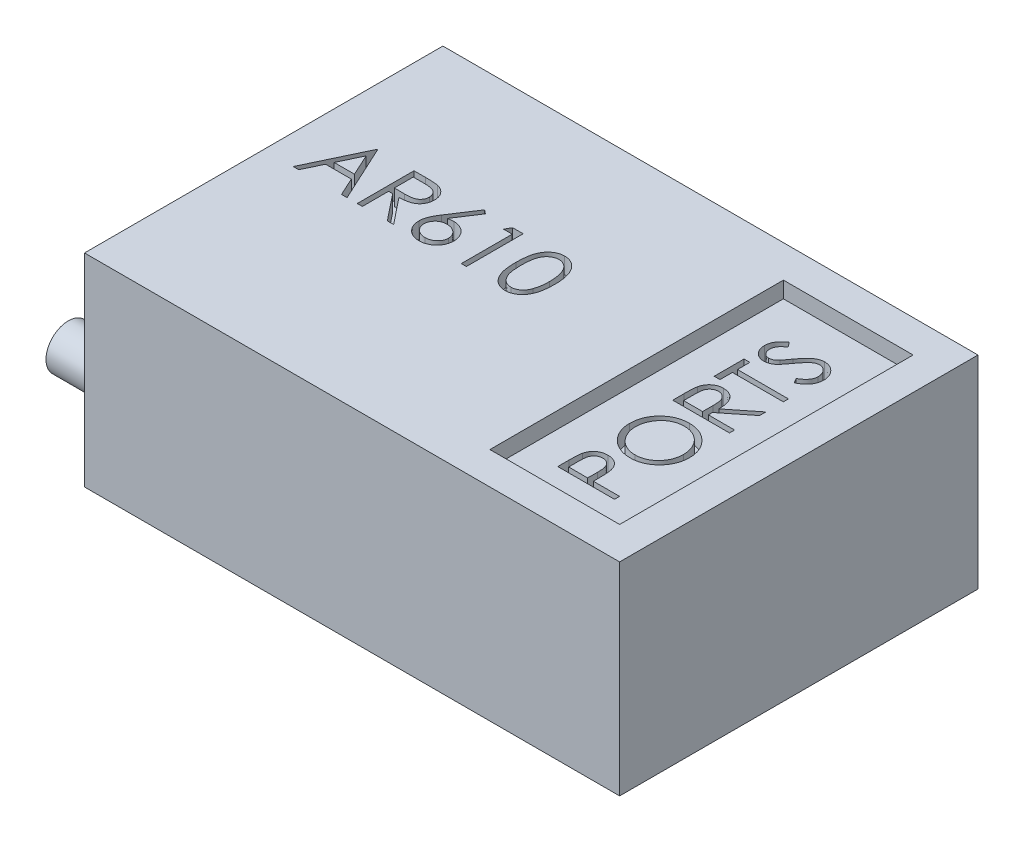
from build123d import *

# Parameters (mm, degrees)
SKETCH1_W           = 33
SKETCH1_H           = 22.1
BOSS_EXTRUDE1_DEPTH = 12.5
CUT_EXTRUDE1_START  = 12.5
SKETCH1_3_W         = 8
SKETCH1_3_H         = 18.1
CUT_EXTRUDE1_DEPTH  = 1
CUT_EXTRUDE2_DEPTH  = 1
CUT_EXTRUDE3_DEPTH  = 1
SKETCH4_R           = 1.375
BOSS_EXTRUDE2_DEPTH = 4
SKETCH5_R           = 1.375
BOSS_EXTRUDE3_DEPTH = 4


with BuildPart() as part:
    # Sketch1 → Boss-Extrude1 (new body)
    with BuildSketch(Plane(origin=(0, 0, 0), x_dir=(1, 0, 0), z_dir=(0, 1, 0))):
        Rectangle(SKETCH1_W, SKETCH1_H)
    extrude(amount=BOSS_EXTRUDE1_DEPTH)

    # Sketch1_3 → Cut-Extrude1 (cut)
    with BuildSketch(Plane(origin=(0, 0, 0), x_dir=(1, 0, 0), z_dir=(0, 1, 0)).offset(CUT_EXTRUDE1_START)):
        with Locations((10.5, 0)):
            Rectangle(SKETCH1_3_W, SKETCH1_3_H)
    extrude(amount=-CUT_EXTRUDE1_DEPTH, mode=Mode.SUBTRACT)

    # Sketch2 → Cut-Extrude2 (cut)
    with BuildSketch(Plane(origin=(0, 11.5, 0), x_dir=(1, 0, 0), z_dir=(0, 1, 0))):
        with BuildLine():
            Line((11.324819712, 4.891025641), (11.147435897, 5.186899038))
            add(Edge.make_bspline(
                [(11.147435897, 5.186899038), (11.193500282, 5.214417276), (11.281757866, 5.267141156), (11.401015907, 5.355092515), (11.502378063, 5.446225427), (11.585254671, 5.54121476), (11.650503558, 5.639480708), (11.696705789, 5.741664762), (11.725521765, 5.847422573), (11.729021851, 5.919396394), (11.730769231, 5.955328526)],
                knots=[0, 0, 0, 0, 0.000160901, 0.00030828, 0.000443778, 0.00056903, 0.000685513, 0.000796284, 0.00090427, 0.001011928, 0.001011928, 0.001011928, 0.001011928], degree=3))
            add(Edge.make_bspline(
                [(11.730769231, 5.955328526), (11.729894225, 5.986009174), (11.728159525, 6.04683363), (11.712164723, 6.13655253), (11.685997262, 6.22325154), (11.650524434, 6.306068819), (11.606920617, 6.382810251), (11.555503534, 6.451184154), (11.496092934, 6.508918667), (11.430889701, 6.556781277), (11.360969967, 6.593817016), (11.288927613, 6.621808988), (11.213774163, 6.637485999), (11.163161674, 6.639838471), (11.137620192, 6.641025641)],
                knots=[0, 0, 0, 0, 9.1978e-05, 0.000182347, 0.000272402, 0.000363175, 0.000452051, 0.000536609, 0.000618912, 0.000699687, 0.000778419, 0.000855638, 0.000930855, 0.001007482, 0.001007482, 0.001007482, 0.001007482], degree=3))
            add(Edge.make_bspline(
                [(11.137620192, 6.641025641), (11.108469616, 6.639582995), (11.049436521, 6.63666148), (10.962191104, 6.610913976), (10.875478842, 6.571598615), (10.821831619, 6.534646594), (10.794070513, 6.51552484)],
                knots=[0, 0, 0, 0, 8.7281e-05, 0.000176753, 0.00027087, 0.000371805, 0.000371805, 0.000371805, 0.000371805], degree=3))
            add(Edge.make_bspline(
                [(10.794070513, 6.51552484), (10.774021155, 6.499856523), (10.731930035, 6.466962851), (10.669329303, 6.410365002), (10.604625858, 6.344289395), (10.536399232, 6.269640382), (10.465216106, 6.186292744), (10.390521004, 6.094214233), (10.313840327, 5.992619013), (10.262479108, 5.921309671), (10.235977564, 5.884515224)],
                knots=[0, 0, 0, 0, 7.6319e-05, 0.000160223, 0.000252933, 0.000353672, 0.000463561, 0.00058171, 0.000709316, 0.00084535, 0.00084535, 0.00084535, 0.00084535], degree=3))
            add(Edge.make_bspline(
                [(10.235977564, 5.884515224), (10.209748976, 5.847691228), (10.159601914, 5.777286552), (10.08517763, 5.678827969), (10.017133761, 5.590783506), (9.954829749, 5.51354449), (9.898257144, 5.447144893), (9.847959205, 5.391061482), (9.802575644, 5.346722925), (9.773134302, 5.322067344), (9.759915865, 5.310997596)],
                knots=[0, 0, 0, 0, 0.000135623, 0.000259301, 0.000370234, 0.000469439, 0.00055697, 0.000631911, 0.000695377, 0.00074709, 0.00074709, 0.00074709, 0.00074709], degree=3))
            add(Edge.make_bspline(
                [(9.759915865, 5.310997596), (9.739313806, 5.295527644), (9.698797091, 5.265103908), (9.635486806, 5.224900947), (9.57080172, 5.190997681), (9.5045074, 5.16371189), (9.437102088, 5.141646905), (9.36807973, 5.12630608), (9.297908891, 5.11685032), (9.250697025, 5.115873567), (9.227063301, 5.115384615)],
                knots=[0, 0, 0, 0, 7.727e-05, 0.000151962, 0.000224716, 0.000296069, 0.000366799, 0.000437219, 0.000507921, 0.00057879, 0.00057879, 0.00057879, 0.00057879], degree=3))
            add(Edge.make_bspline(
                [(9.227063301, 5.115384615), (9.190033454, 5.116689766), (9.116765247, 5.119272171), (9.009735467, 5.141113532), (8.907545135, 5.175583284), (8.811229505, 5.223889972), (8.723208531, 5.28610319), (8.642689941, 5.358412416), (8.574076388, 5.443739272), (8.515061523, 5.538202444), (8.468392297, 5.641056543), (8.434570946, 5.749339544), (8.414481488, 5.862273073), (8.411678608, 5.938889047), (8.41025641, 5.977764423)],
                knots=[0, 0, 0, 0, 0.000110999, 0.000219625, 0.000326272, 0.00043382, 0.000541574, 0.000648775, 0.000757401, 0.00086888, 0.000982145, 0.001095241, 0.001208435, 0.001325032, 0.001325032, 0.001325032, 0.001325032], degree=3))
            add(Edge.make_bspline(
                [(8.41025641, 5.977764423), (8.411659646, 6.019015202), (8.414450233, 6.101049834), (8.439317515, 6.221525554), (8.478894919, 6.337993167), (8.525329582, 6.431268407), (8.571411516, 6.504424807), (8.613476125, 6.560159904), (8.661802416, 6.616946088), (8.717409181, 6.67417308), (8.779184228, 6.732405827), (8.84765049, 6.791376095), (8.922190972, 6.851635747), (8.975417749, 6.890389429), (9.002704327, 6.91025641)],
                knots=[0, 0, 0, 0, 0.000123638, 0.000245877, 0.00036738, 0.00049186, 0.00055741, 0.000626541, 0.000701144, 0.000780976, 0.000865789, 0.000955754, 0.001052002, 0.001153245, 0.001153245, 0.001153245, 0.001153245], degree=3))
            Line((9.002704327, 6.91025641), (9.217948718, 6.626302083))
            add(Edge.make_bspline(
                [(9.217948718, 6.626302083), (9.195858749, 6.609157401), (9.153318634, 6.576140751), (9.093764323, 6.525994636), (9.039290221, 6.478802335), (8.992099661, 6.431950702), (8.948658829, 6.389051048), (8.912126496, 6.346674872), (8.881348415, 6.306457476), (8.84844255, 6.255885213), (8.816810731, 6.191821741), (8.789025896, 6.112073028), (8.772542449, 6.0284507), (8.770343811, 5.971525978), (8.769230769, 5.942708333)],
                knots=[0, 0, 0, 0, 8.3877e-05, 0.000161528, 0.000233552, 0.000299993, 0.000360974, 0.000416642, 0.000467684, 0.000512802, 0.000597461, 0.000681273, 0.000765563, 0.000851983, 0.000851983, 0.000851983, 0.000851983], degree=3))
            add(Edge.make_bspline(
                [(8.769230769, 5.942708333), (8.770422628, 5.906543278), (8.772721016, 5.836802377), (8.79848339, 5.738021386), (8.837653343, 5.648599939), (8.894136008, 5.571951683), (8.961474223, 5.508664408), (9.038268715, 5.462316711), (9.123085244, 5.434606238), (9.182222228, 5.431214525), (9.212339744, 5.429487179)],
                knots=[0, 0, 0, 0, 0.000108248, 0.000208746, 0.00030414, 0.000399502, 0.000492276, 0.000579692, 0.000666608, 0.000756813, 0.000756813, 0.000756813, 0.000756813], degree=3))
            add(Edge.make_bspline(
                [(9.212339744, 5.429487179), (9.231086922, 5.429902764), (9.268842435, 5.430739723), (9.324357544, 5.441434705), (9.37957994, 5.4558952), (9.434315268, 5.478063832), (9.489802974, 5.508935487), (9.546826776, 5.549432487), (9.605877844, 5.600448334), (9.644285314, 5.639524965), (9.664563301, 5.66015625)],
                knots=[0, 0, 0, 0, 5.616e-05, 0.000113102, 0.00016906, 0.000227257, 0.000289705, 0.000359147, 0.000436716, 0.000523477, 0.000523477, 0.000523477, 0.000523477], degree=3))
            add(Edge.make_bspline(
                [(9.664563301, 5.66015625), (9.671400327, 5.667817622), (9.687643535, 5.68601929), (9.714235816, 5.719295215), (9.747038588, 5.763238014), (9.787625905, 5.816700215), (9.834707367, 5.880667576), (9.887680979, 5.955147133), (9.948266438, 6.039308665), (9.990623979, 6.099030581), (10.013020833, 6.130608974)],
                knots=[0, 0, 0, 0, 3.0802e-05, 7.3177e-05, 0.000127725, 0.000195314, 0.000274544, 0.000365991, 0.000469501, 0.000585644, 0.000585644, 0.000585644, 0.000585644], degree=3))
            add(Edge.make_bspline(
                [(10.013020833, 6.130608974), (10.040662212, 6.168594861), (10.094185912, 6.242149265), (10.174601328, 6.346807208), (10.253250001, 6.441699774), (10.32962457, 6.527167148), (10.403162781, 6.60403017), (10.474692352, 6.671514016), (10.543744202, 6.729924878), (10.631670956, 6.79366713), (10.740659387, 6.858027909), (10.874250962, 6.913211987), (11.008225903, 6.948319153), (11.098156806, 6.952878605), (11.142528045, 6.955128205)],
                knots=[0, 0, 0, 0, 0.000140932, 0.000272896, 0.000395881, 0.000510584, 0.000616697, 0.000714904, 0.000805482, 0.000887803, 0.001040519, 0.001183872, 0.00132042, 0.001453406, 0.001453406, 0.001453406, 0.001453406], degree=3))
            add(Edge.make_bspline(
                [(11.142528045, 6.955128205), (11.173906078, 6.954470397), (11.236052803, 6.953167556), (11.327312713, 6.938216381), (11.415925606, 6.916260494), (11.500708518, 6.883434617), (11.583021811, 6.842716087), (11.661314865, 6.791788931), (11.737108745, 6.732449155), (11.808278554, 6.664414283), (11.873692779, 6.590006612), (11.931641285, 6.511079761), (11.981071825, 6.428457656), (12.020438404, 6.341245554), (12.051434888, 6.250380345), (12.073830506, 6.155562389), (12.087590898, 6.056695638), (12.089018015, 5.989494776), (12.08974359, 5.955328526)],
                knots=[0, 0, 0, 0, 9.4044e-05, 0.000186263, 0.000276729, 0.000367488, 0.000458418, 0.00055177, 0.000647146, 0.000746826, 0.000846684, 0.000944006, 0.0010402, 0.001134956, 0.001230517, 0.001327791, 0.001426848, 0.001529298, 0.001529298, 0.001529298, 0.001529298], degree=3))
            add(Edge.make_bspline(
                [(12.08974359, 5.955328526), (12.089232408, 5.928893183), (12.088216483, 5.876355423), (12.079235203, 5.79864594), (12.066528096, 5.722506355), (12.046354038, 5.648892058), (12.021877016, 5.5768547), (11.991738854, 5.506707265), (11.955621006, 5.43841697), (11.914328466, 5.371596474), (11.866261053, 5.306433633), (11.810326101, 5.243468982), (11.747949935, 5.181046097), (11.67816895, 5.119607785), (11.600215796, 5.060494436), (11.515251617, 5.002286928), (11.42302375, 4.945268932), (11.358165806, 4.909444455), (11.324819712, 4.891025641)],
                knots=[0, 0, 0, 0, 7.9276e-05, 0.000157554, 0.000234438, 0.000310629, 0.000386236, 0.000462555, 0.000539392, 0.000617798, 0.000698008, 0.000781971, 0.000870217, 0.000962622, 0.001060644, 0.00116352, 0.001271506, 0.001385778, 0.001385778, 0.001385778, 0.001385778], degree=3))
        make_face()
        Polygon((8.858974359, 2.782051282), (8.5, 2.782051282), (8.5, 4.621794872), (8.858974359, 4.621794872), (8.858974359, 3.858974359), (12, 3.858974359), (12, 3.544871795), (8.858974359, 3.544871795), align=None)
        with BuildLine():
            Line((8.5, 0.224358974), (8.5, 0.924779647))
            add(Edge.make_bspline(
                [(8.5, 0.924779647), (8.500155586, 0.971520776), (8.500454328, 1.06126892), (8.502120091, 1.189842191), (8.506894447, 1.306669288), (8.51100303, 1.411689127), (8.518494972, 1.504899782), (8.525655619, 1.586587073), (8.53502928, 1.65637477), (8.543734703, 1.698620622), (8.547676282, 1.717748397)],
                knots=[0, 0, 0, 0, 0.000140226, 0.00026925, 0.000385712, 0.000490995, 0.000584507, 0.000666202, 0.000736998, 0.000795574, 0.000795574, 0.000795574, 0.000795574], degree=3))
            add(Edge.make_bspline(
                [(8.547676282, 1.717748397), (8.554003064, 1.743355002), (8.566521662, 1.794021952), (8.592981015, 1.866972307), (8.623601552, 1.936485565), (8.659561947, 2.002279275), (8.701149074, 2.064000637), (8.747570963, 2.122372975), (8.798733851, 2.17720681), (8.855098955, 2.227786515), (8.915465334, 2.273730647), (8.979667312, 2.314030727), (9.047439425, 2.348083554), (9.118887235, 2.374806282), (9.193221492, 2.397229588), (9.271200889, 2.412295287), (9.352565107, 2.421679745), (9.407926436, 2.422606838), (9.435997596, 2.423076923)],
                knots=[0, 0, 0, 0, 7.9081e-05, 0.000156475, 0.000232432, 0.000306798, 0.00038108, 0.000455429, 0.000530331, 0.000605792, 0.000682355, 0.00075764, 0.000832893, 0.000909456, 0.000986216, 0.001065554, 0.001147393, 0.001231575, 0.001231575, 0.001231575, 0.001231575], degree=3))
            add(Edge.make_bspline(
                [(9.435997596, 2.423076923), (9.482632701, 2.421607925), (9.573629869, 2.418741529), (9.70569075, 2.392016425), (9.828880065, 2.348239906), (9.943042703, 2.287916617), (10.045953348, 2.211097141), (10.136343803, 2.11877235), (10.211983716, 2.010890738), (10.264436521, 1.910461423), (10.298029429, 1.821747223), (10.321665788, 1.74871391), (10.339927753, 1.669046933), (10.356287885, 1.583509598), (10.36863958, 1.491745942), (10.377686174, 1.393975903), (10.383340223, 1.290129751), (10.384182228, 1.218790682), (10.384615385, 1.182091346)],
                knots=[0, 0, 0, 0, 0.000139777, 0.000272741, 0.000402249, 0.000530843, 0.000658588, 0.000786009, 0.000916741, 0.001052522, 0.001124656, 0.001201155, 0.001282612, 0.001369656, 0.001462366, 0.001560247, 0.001664165, 0.001774261, 0.001774261, 0.001774261, 0.001774261], degree=3))
            Line((10.384615385, 1.182091346), (12, 2.467948718))
            Line((12, 2.467948718), (12, 2.079527244))
            Line((12, 2.079527244), (10.384615385, 0.793669872))
            Line((10.384615385, 0.793669872), (10.384615385, 0.538461538))
            Line((10.384615385, 0.538461538), (12, 0.538461538))
            Line((12, 0.538461538), (12, 0.224358974))
            Line((12, 0.224358974), (8.5, 0.224358974))
        make_face()
        with BuildLine():
            Line((8.858974359, 0.538461538), (10.025641026, 0.538461538))
            Line((10.025641026, 0.538461538), (10.030548878, 1.179286859))
            add(Edge.make_bspline(
                [(10.030548878, 1.179286859), (10.030562123, 1.209206902), (10.030587794, 1.267200466), (10.026593914, 1.351101079), (10.02205095, 1.42922137), (10.015100421, 1.501261523), (10.006148236, 1.567257067), (9.994932575, 1.627164059), (9.981921822, 1.681116033), (9.961575546, 1.743835854), (9.930748318, 1.814700234), (9.882868093, 1.890030588), (9.825336481, 1.95612693), (9.757650075, 2.009957492), (9.68441132, 2.055058732), (9.604870116, 2.085410073), (9.521606702, 2.105637954), (9.464398252, 2.107849402), (9.435296474, 2.108974359)],
                knots=[0, 0, 0, 0, 8.9746e-05, 0.000173954, 0.000251933, 0.000324488, 0.000391021, 0.000451663, 0.000507268, 0.000557378, 0.000649353, 0.000738241, 0.000824182, 0.000910906, 0.000996758, 0.001081126, 0.001165314, 0.001252481, 0.001252481, 0.001252481, 0.001252481], degree=3))
            add(Edge.make_bspline(
                [(9.435296474, 2.108974359), (9.407152196, 2.107768768), (9.351380505, 2.105379727), (9.269690948, 2.085981825), (9.192568424, 2.052819171), (9.119913357, 2.009193553), (9.054992053, 1.954443216), (8.998841303, 1.891478684), (8.952874184, 1.820312076), (8.922322772, 1.754383063), (8.904381275, 1.694982342), (8.891340833, 1.643653307), (8.88229028, 1.585371229), (8.873717756, 1.520401159), (8.866778066, 1.448619104), (8.861991163, 1.369814677), (8.859187737, 1.284476047), (8.85904714, 1.225329383), (8.858974359, 1.194711538)],
                knots=[0, 0, 0, 0, 8.4371e-05, 0.000167192, 0.000250141, 0.000335393, 0.000420495, 0.000503932, 0.000587553, 0.000673837, 0.000720849, 0.000773564, 0.000832579, 0.000897628, 0.000970183, 0.001048862, 0.001134445, 0.001226295, 0.001226295, 0.001226295, 0.001226295], degree=3))
            Line((8.858974359, 1.194711538), (8.858974359, 0.538461538))
        make_face(mode=Mode.SUBTRACT)
        with BuildLine():
            add(Edge.make_bspline(
                [(8.41025641, -2.355769231), (8.411870256, -2.290954059), (8.415039982, -2.163651713), (8.440104769, -1.976730191), (8.481358785, -1.797744453), (8.539618265, -1.6265916), (8.615144359, -1.463922571), (8.706886934, -1.309277945), (8.815403528, -1.163121176), (8.939100677, -1.02645832), (9.074569243, -0.901790135), (9.219590912, -0.792393155), (9.37234238, -0.700106479), (9.532831612, -0.624559783), (9.700683913, -0.56525062), (9.876840006, -0.524334454), (10.060146125, -0.498195518), (10.185173068, -0.495139848), (10.248597756, -0.493589744)],
                knots=[0, 0, 0, 0, 0.000194393, 0.000381804, 0.00056463, 0.000744667, 0.000923157, 0.001101717, 0.001283171, 0.001468332, 0.001653919, 0.001834669, 0.002012386, 0.002188335, 0.002365952, 0.002545365, 0.00273009, 0.002920281, 0.002920281, 0.002920281, 0.002920281], degree=3))
            add(Edge.make_bspline(
                [(10.248597756, -0.493589744), (10.311554876, -0.49514037), (10.435650654, -0.498196835), (10.617798777, -0.524355663), (10.792872295, -0.56543319), (10.960480991, -0.623825455), (11.120644264, -0.699430122), (11.273511369, -0.791852658), (11.418920391, -0.901042015), (11.555322226, -1.025180795), (11.680098323, -1.160907431), (11.7901557, -1.30537174), (11.88248255, -1.458119134), (11.958872657, -1.617566699), (12.016945826, -1.784966468), (12.05922501, -1.959100269), (12.085104461, -2.140916842), (12.088180245, -2.264771892), (12.08974359, -2.327724359)],
                knots=[0, 0, 0, 0, 0.000188789, 0.000372126, 0.000550857, 0.00072758, 0.000903529, 0.001081247, 0.001262557, 0.001448189, 0.001633775, 0.001814947, 0.001992065, 0.002168314, 0.002344376, 0.002522589, 0.002705231, 0.00289402, 0.00289402, 0.00289402, 0.00289402], degree=3))
            add(Edge.make_bspline(
                [(12.08974359, -2.327724359), (12.088194203, -2.391148678), (12.085139949, -2.516174894), (12.058958544, -2.699711929), (12.01801724, -2.875989673), (11.959507804, -3.044504024), (11.883890573, -3.205348954), (11.791686194, -3.358839037), (11.682279053, -3.504358184), (11.558112479, -3.64069993), (11.422940927, -3.765449129), (11.278106671, -3.874208504), (11.126451215, -3.966433618), (10.967553691, -4.04179695), (10.802182248, -4.101461409), (10.629233771, -4.142166228), (10.449694265, -4.16850218), (10.327451366, -4.171537026), (10.265424679, -4.173076923)],
                knots=[0, 0, 0, 0, 0.00019019, 0.000374915, 0.000555011, 0.000732396, 0.00090898, 0.001087298, 0.001268608, 0.00145424, 0.001639827, 0.001819595, 0.001996712, 0.002171394, 0.002346367, 0.002523053, 0.002703612, 0.002889599, 0.002889599, 0.002889599, 0.002889599], degree=3))
            add(Edge.make_bspline(
                [(10.265424679, -4.173076923), (10.22379201, -4.172542288), (10.141051887, -4.171479761), (10.018185287, -4.158688069), (9.897294629, -4.140126368), (9.778723681, -4.113524455), (9.662762696, -4.078732788), (9.548611933, -4.037680761), (9.43742821, -3.987540915), (9.328684818, -3.930860267), (9.224076912, -3.867598459), (9.125197329, -3.79772271), (9.031216332, -3.723687341), (8.944569328, -3.642523948), (8.862735672, -3.556907502), (8.786972955, -3.465449124), (8.716598004, -3.36870688), (8.653177663, -3.2662645), (8.595818528, -3.160646225), (8.546596677, -3.051769448), (8.504350616, -2.941112876), (8.470109791, -2.828158228), (8.443077755, -2.713205456), (8.424670401, -2.596003671), (8.411846083, -2.476646245), (8.410788581, -2.396234926), (8.41025641, -2.355769231)],
                knots=[0, 0, 0, 0, 0.000124849, 0.000248123, 0.000370193, 0.00049164, 0.000612319, 0.000733199, 0.000855287, 0.000977905, 0.001100913, 0.001221706, 0.001340948, 0.001459521, 0.001577551, 0.001696047, 0.001815534, 0.001936153, 0.002057243, 0.002175846, 0.002294342, 0.002412335, 0.002529682, 0.00264829, 0.002768075, 0.00288942, 0.00288942, 0.00288942, 0.00288942], degree=3))
        make_face()
        with BuildLine():
            add(Edge.make_bspline(
                [(8.769230769, -2.340344551), (8.769634247, -2.37355961), (8.770437346, -2.439672188), (8.78107394, -2.537950444), (8.796125217, -2.634966024), (8.817984948, -2.730531189), (8.846259561, -2.824846358), (8.880360976, -2.917953402), (8.921577647, -3.009533089), (8.967930801, -3.099471009), (9.020580569, -3.185689891), (9.07648948, -3.268397375), (9.137734853, -3.345442169), (9.202992164, -3.417882654), (9.272827745, -3.485538676), (9.346782977, -3.548380394), (9.425177738, -3.606356274), (9.507689399, -3.658768603), (9.59385728, -3.705411484), (9.682034222, -3.747172811), (9.773256487, -3.781791358), (9.866954822, -3.809214404), (9.962716319, -3.832490288), (10.06106272, -3.847090644), (10.161654991, -3.857832041), (10.229637232, -3.858590655), (10.264022436, -3.858974359)],
                knots=[0, 0, 0, 0, 9.9599e-05, 0.000198245, 0.000296222, 0.00039402, 0.000492067, 0.000591444, 0.000691249, 0.000793166, 0.00089477, 0.000994144, 0.001092474, 0.001189771, 0.001286457, 0.001383951, 0.001480708, 0.001578737, 0.001676939, 0.001774486, 0.001871236, 0.001969283, 0.002067239, 0.002166601, 0.002267341, 0.002370444, 0.002370444, 0.002370444, 0.002370444], degree=3))
            add(Edge.make_bspline(
                [(10.264022436, -3.858974359), (10.314583507, -3.85769658), (10.414052776, -3.855182794), (10.559837321, -3.83326684), (10.700078846, -3.799240157), (10.833941455, -3.749907894), (10.962022079, -3.686974857), (11.083822274, -3.610209329), (11.19930611, -3.518908299), (11.307613927, -3.415259346), (11.406431406, -3.301921948), (11.49329249, -3.181631994), (11.566397201, -3.055341173), (11.627511096, -2.923777392), (11.673551763, -2.785817383), (11.706378736, -2.642345692), (11.727654831, -2.493359149), (11.729721246, -2.391833454), (11.730769231, -2.340344551)],
                knots=[0, 0, 0, 0, 0.000151605, 0.000298253, 0.000441263, 0.000583887, 0.000725302, 0.000868664, 0.001014957, 0.001166206, 0.001317773, 0.001465459, 0.001610604, 0.001754915, 0.001899916, 0.002046009, 0.002196031, 0.002350407, 0.002350407, 0.002350407, 0.002350407], degree=3))
            add(Edge.make_bspline(
                [(11.730769231, -2.340344551), (11.73029411, -2.305734913), (11.729351803, -2.237093607), (11.719847504, -2.13500008), (11.704636733, -2.034736379), (11.682628178, -1.936487754), (11.655447833, -1.84012548), (11.621733416, -1.745940317), (11.581317911, -1.653963545), (11.536276167, -1.563742896), (11.485109961, -1.477298497), (11.429954753, -1.395092698), (11.369790032, -1.31818064), (11.305409155, -1.245774143), (11.235788248, -1.178592275), (11.162282468, -1.115929481), (11.083721323, -1.05895602), (11.00154761, -1.00672137), (10.916007946, -0.959509375), (10.827588586, -0.918956006), (10.736763755, -0.884322589), (10.643466721, -0.856404132), (10.547907348, -0.834515957), (10.449948869, -0.819436774), (10.349789635, -0.808888136), (10.282045764, -0.808093086), (10.247896635, -0.807692308)],
                knots=[0, 0, 0, 0, 0.000103804, 0.000205874, 0.000307314, 0.000407849, 0.000507719, 0.000607515, 0.00070768, 0.000808957, 0.000909843, 0.001008823, 0.001105735, 0.001202564, 0.00129925, 0.001395755, 0.001492098, 0.001590127, 0.001687714, 0.001784966, 0.001881715, 0.00197909, 0.002076889, 0.002175558, 0.002276298, 0.0023787, 0.0023787, 0.0023787, 0.0023787], degree=3))
            add(Edge.make_bspline(
                [(10.247896635, -0.807692308), (10.21398113, -0.808093421), (10.14670348, -0.808889102), (10.047242662, -0.819431577), (9.94998945, -0.834532467), (9.855325648, -0.856295175), (9.763227121, -0.884345328), (9.673780379, -0.918932662), (9.586652163, -0.959717948), (9.502057945, -1.006526226), (9.420882913, -1.059141849), (9.34328159, -1.116636835), (9.270704782, -1.179999411), (9.201385299, -1.247435805), (9.136709676, -1.320567335), (9.076927808, -1.399406764), (9.019346124, -1.481991093), (8.968385696, -1.570187906), (8.9210882, -1.660883674), (8.880736177, -1.754033316), (8.846079504, -1.848306518), (8.817900543, -1.944080203), (8.79620895, -2.041309099), (8.781060471, -2.139936664), (8.770441, -2.239618633), (8.76963546, -2.306662699), (8.769230769, -2.340344551)],
                knots=[0, 0, 0, 0, 0.000101701, 0.000201743, 0.00029972, 0.000396835, 0.000492868, 0.000588308, 0.000684288, 0.000781261, 0.000878109, 0.000974304, 0.001070733, 0.001166917, 0.001264269, 0.001363274, 0.001463623, 0.001566073, 0.001668612, 0.001770342, 0.001870377, 0.001969768, 0.002069618, 0.00216898, 0.002269022, 0.002370022, 0.002370022, 0.002370022, 0.002370022], degree=3))
        make_face(mode=Mode.SUBTRACT)
        with BuildLine():
            Line((8.5, -6.865384615), (8.5, -6.178986378))
            add(Edge.make_bspline(
                [(8.5, -6.178986378), (8.500051896, -6.131775472), (8.500151332, -6.041317279), (8.503166078, -5.911602224), (8.50719277, -5.793792492), (8.512774663, -5.688142111), (8.519371253, -5.594326013), (8.528623292, -5.512768713), (8.538283588, -5.442829157), (8.548104995, -5.400922708), (8.552584135, -5.381810897)],
                knots=[0, 0, 0, 0, 0.000141628, 0.000271366, 0.00038923, 0.000495248, 0.00058876, 0.000671296, 0.000741499, 0.00080036, 0.00080036, 0.00080036, 0.00080036], degree=3))
            add(Edge.make_bspline(
                [(8.552584135, -5.381810897), (8.559206344, -5.357617575), (8.572294717, -5.309801014), (8.598504692, -5.240896918), (8.629600774, -5.175354407), (8.664973264, -5.112880947), (8.706363357, -5.054614393), (8.751017547, -4.998612397), (8.801821577, -4.946851825), (8.857173072, -4.898631589), (8.916370005, -4.854062962), (8.980487907, -4.816617256), (9.047612511, -4.783875897), (9.118656095, -4.757068886), (9.193687635, -4.737134078), (9.272173907, -4.722334492), (9.354203167, -4.712897729), (9.410263789, -4.711996992), (9.438802083, -4.711538462)],
                knots=[0, 0, 0, 0, 7.5216e-05, 0.00014866, 0.000220794, 0.000292713, 0.000363707, 0.00043499, 0.000507379, 0.00058092, 0.0006551, 0.00072929, 0.000803294, 0.000878953, 0.00095668, 0.001035885, 0.001118421, 0.001204004, 0.001204004, 0.001204004, 0.001204004], degree=3))
            add(Edge.make_bspline(
                [(9.438802083, -4.711538462), (9.46757986, -4.711959886), (9.523885524, -4.712784432), (9.606258312, -4.722680718), (9.684976702, -4.736010909), (9.759866153, -4.756507961), (9.830481923, -4.783353635), (9.897903155, -4.814845687), (9.960982827, -4.852829218), (10.019949945, -4.896474048), (10.074859857, -4.945025642), (10.125314652, -4.99827858), (10.17101899, -5.056017873), (10.212075334, -5.118060021), (10.247531613, -5.185009869), (10.279288918, -5.255852023), (10.305959979, -5.331202239), (10.31999004, -5.383344753), (10.327123397, -5.409855769)],
                knots=[0, 0, 0, 0, 8.6284e-05, 0.00016882, 0.000248587, 0.000325638, 0.000401297, 0.000474998, 0.000548586, 0.000621785, 0.0006948, 0.0007682, 0.000841564, 0.000915458, 0.000991056, 0.00106858, 0.00114819, 0.001230532, 0.001230532, 0.001230532, 0.001230532], degree=3))
            add(Edge.make_bspline(
                [(10.327123397, -5.409855769), (10.331782903, -5.431783353), (10.341994481, -5.479838927), (10.353472009, -5.558976687), (10.362884836, -5.65116331), (10.371668962, -5.756085135), (10.37632345, -5.873986838), (10.381788578, -6.004598009), (10.384367274, -6.14836068), (10.384530279, -6.248630661), (10.384615385, -6.300981571)],
                knots=[0, 0, 0, 0, 6.7238e-05, 0.000147357, 0.000239727, 0.000345231, 0.000463153, 0.000593654, 0.000737411, 0.000894464, 0.000894464, 0.000894464, 0.000894464], degree=3))
            Line((10.384615385, -6.300981571), (10.384615385, -6.551282051))
            Line((10.384615385, -6.551282051), (12, -6.551282051))
            Line((12, -6.551282051), (12, -6.865384615))
            Line((12, -6.865384615), (8.5, -6.865384615))
        make_face()
        with BuildLine():
            Line((8.858974359, -6.551282051), (10.025641026, -6.551282051))
            Line((10.025641026, -6.551282051), (10.033353365, -5.938501603))
            add(Edge.make_bspline(
                [(10.033353365, -5.938501603), (10.033369841, -5.908581468), (10.033401646, -5.850821264), (10.029402888, -5.767387839), (10.024848287, -5.689969055), (10.017959717, -5.61885604), (10.008929892, -5.553799271), (9.997700403, -5.49536068), (9.985492161, -5.442666223), (9.965095217, -5.382051459), (9.933732824, -5.313918466), (9.888077864, -5.239488373), (9.828934043, -5.1768982), (9.762621316, -5.122835038), (9.68904981, -5.079087992), (9.609918632, -5.048226197), (9.526400101, -5.029222777), (9.469284935, -5.026849432), (9.440204327, -5.025641026)],
                knots=[0, 0, 0, 0, 8.9746e-05, 0.000173253, 0.000250533, 0.00032239, 0.000387534, 0.000447487, 0.000500883, 0.00054966, 0.000639077, 0.000725438, 0.000810285, 0.000896023, 0.000981517, 0.001065885, 0.001149917, 0.001237085, 0.001237085, 0.001237085, 0.001237085], degree=3))
            add(Edge.make_bspline(
                [(9.440204327, -5.025641026), (9.412065841, -5.026903685), (9.356130013, -5.029413694), (9.274150847, -5.048069373), (9.19591669, -5.079419391), (9.122937667, -5.122873284), (9.056770854, -5.175624417), (8.999194105, -5.236887546), (8.953217687, -5.306819403), (8.922399559, -5.371329886), (8.904356633, -5.42909823), (8.891324885, -5.47902804), (8.882338596, -5.535692535), (8.873739839, -5.598553316), (8.866798926, -5.667530572), (8.861978891, -5.743062707), (8.859187578, -5.824898191), (8.859047153, -5.881708495), (8.858974359, -5.911157853)],
                knots=[0, 0, 0, 0, 8.4371e-05, 0.000167719, 0.000250783, 0.000336277, 0.000421575, 0.000503926, 0.000587348, 0.000671722, 0.000717397, 0.000768752, 0.000826385, 0.000889349, 0.000959113, 0.001034294, 0.001116373, 0.001204717, 0.001204717, 0.001204717, 0.001204717], degree=3))
            Line((8.858974359, -5.911157853), (8.858974359, -6.551282051))
        make_face(mode=Mode.SUBTRACT)
    extrude(amount=-CUT_EXTRUDE2_DEPTH, mode=Mode.SUBTRACT)

    # Sketch3 → Cut-Extrude3 (cut)
    with BuildSketch(Plane(origin=(0, 12.5, 0), x_dir=(1, 0, 0), z_dir=(0, 1, 0))):
        with BuildLine():
            add(Edge.make_bspline(
                [(-2.698717949, 1.748597756), (-2.698389931, 1.804695144), (-2.697752751, 1.913665128), (-2.69066433, 2.07244977), (-2.678888987, 2.221410059), (-2.662751614, 2.360553125), (-2.643113634, 2.48991489), (-2.616898148, 2.609149647), (-2.587085345, 2.718809254), (-2.552532899, 2.819251302), (-2.51354511, 2.911829005), (-2.471110849, 2.998254207), (-2.423546055, 3.078396139), (-2.373569142, 3.153533929), (-2.31915707, 3.222437624), (-2.26185828, 3.286080287), (-2.199436404, 3.342991037), (-2.134013395, 3.394837339), (-2.064996931, 3.440286811), (-1.994354265, 3.48031955), (-1.921599159, 3.514519417), (-1.846532976, 3.541409853), (-1.769830418, 3.5636207), (-1.691223352, 3.578809647), (-1.610581988, 3.588366556), (-1.556150553, 3.589280224), (-1.528545673, 3.58974359)],
                knots=[0, 0, 0, 0, 0.000168282, 0.000326891, 0.000476705, 0.00061646, 0.000747059, 0.00086904, 0.000982494, 0.001087814, 0.001187428, 0.001283689, 0.001376399, 0.001466822, 0.001554203, 0.001639568, 0.001723424, 0.001807301, 0.001889751, 0.001971063, 0.002050735, 0.002130583, 0.002210036, 0.002290062, 0.002370508, 0.002453288, 0.002453288, 0.002453288, 0.002453288], degree=3))
            add(Edge.make_bspline(
                [(-1.528545673, 3.58974359), (-1.500710195, 3.589255775), (-1.445354186, 3.588285664), (-1.36351381, 3.578961721), (-1.283564129, 3.563490598), (-1.20584599, 3.541569623), (-1.129721004, 3.514373947), (-1.055784596, 3.48028683), (-0.983577514, 3.440607962), (-0.914247227, 3.393984085), (-0.847032611, 3.342001809), (-0.783584648, 3.28323914), (-0.723897563, 3.218289421), (-0.667222257, 3.147847557), (-0.61516666, 3.070562472), (-0.565593228, 2.987778362), (-0.521221192, 2.898047497), (-0.478486517, 2.80286703), (-0.44159953, 2.699603371), (-0.408333285, 2.58883861), (-0.381454316, 2.469264423), (-0.359065044, 2.341508178), (-0.341720148, 2.205100695), (-0.329087506, 2.060334379), (-0.322414421, 1.907113989), (-0.321157719, 1.80235614), (-0.320512821, 1.748597756)],
                knots=[0, 0, 0, 0, 8.3481e-05, 0.000166017, 0.000246731, 0.000327534, 0.000408041, 0.000488986, 0.000571522, 0.000654944, 0.000739373, 0.000826202, 0.000914021, 0.001003809, 0.001097153, 0.001193347, 0.001293057, 0.001397277, 0.001506176, 0.001621751, 0.001744038, 0.001873599, 0.002010742, 0.002156422, 0.002309427, 0.002470709, 0.002470709, 0.002470709, 0.002470709], degree=3))
            add(Edge.make_bspline(
                [(-0.320512821, 1.748597756), (-0.321164405, 1.695073848), (-0.322433991, 1.590784697), (-0.329012698, 1.438253721), (-0.341971329, 1.294255678), (-0.358181317, 1.158445216), (-0.38063228, 1.031387597), (-0.408237446, 0.912643148), (-0.438887769, 0.801699077), (-0.476722563, 0.699464265), (-0.518133274, 0.604512542), (-0.56318847, 0.515845394), (-0.611458296, 0.432679101), (-0.664047041, 0.355679354), (-0.720100454, 0.284300697), (-0.780818243, 0.219803074), (-0.844488828, 0.160632402), (-0.911901244, 0.107980775), (-0.982312795, 0.06189597), (-1.054271872, 0.02068212), (-1.129055255, -0.012550575), (-1.204968208, -0.041085616), (-1.283096574, -0.062886068), (-1.363342965, -0.077959923), (-1.445299201, -0.088531772), (-1.500700766, -0.089338252), (-1.528545673, -0.08974359)],
                knots=[0, 0, 0, 0, 0.000160581, 0.000312886, 0.000457868, 0.000594226, 0.000723097, 0.000844701, 0.000959884, 0.001068125, 0.001171421, 0.001270505, 0.001366343, 0.001459687, 0.001550023, 0.00163832, 0.001725149, 0.001810562, 0.001894568, 0.001977446, 0.00205903, 0.002139777, 0.00222058, 0.002301983, 0.002384599, 0.00246808, 0.00246808, 0.00246808, 0.00246808], degree=3))
            add(Edge.make_bspline(
                [(-1.528545673, -0.08974359), (-1.556149787, -0.089277234), (-1.610579712, -0.088357672), (-1.691232137, -0.078843941), (-1.769514581, -0.063548438), (-1.845813335, -0.042131834), (-1.92051985, -0.015916997), (-1.992616136, 0.018236686), (-2.06290382, 0.057570755), (-2.131195376, 0.102366177), (-2.196207537, 0.15368786), (-2.258306143, 0.210452149), (-2.315931162, 0.27407556), (-2.369565257, 0.343553483), (-2.420539345, 0.418246725), (-2.467428719, 0.499175098), (-2.510799573, 0.586017709), (-2.550443064, 0.67933562), (-2.585591727, 0.780490547), (-2.616639435, 0.890639726), (-2.641153593, 1.010755362), (-2.662136548, 1.139872729), (-2.679060931, 1.278546659), (-2.690615256, 1.426852438), (-2.697756571, 1.584697647), (-2.698391642, 1.692967421), (-2.698717949, 1.748597756)],
                knots=[0, 0, 0, 0, 8.278e-05, 0.000163226, 0.000243252, 0.00032184, 0.00040079, 0.000480463, 0.00056082, 0.000642298, 0.000725191, 0.000809047, 0.000894412, 0.000982346, 0.001072188, 0.001165503, 0.001262704, 0.001363236, 0.001469448, 0.001583766, 0.001706286, 0.001836995, 0.001976138, 0.002125253, 0.002283161, 0.002450041, 0.002450041, 0.002450041, 0.002450041], degree=3))
        make_face()
        with BuildLine():
            add(Edge.make_bspline(
                [(-2.384615385, 1.75), (-2.384495938, 1.703251301), (-2.384264114, 1.612521256), (-2.378207914, 1.480677995), (-2.369957682, 1.357707667), (-2.359316384, 1.24345413), (-2.343513436, 1.138304118), (-2.325806648, 1.041534435), (-2.304258559, 0.953657197), (-2.278763541, 0.874069387), (-2.249724444, 0.801420318), (-2.21801858, 0.733819103), (-2.183957857, 0.670467167), (-2.145838707, 0.611933558), (-2.104323643, 0.558027394), (-2.060350384, 0.507794562), (-2.0122778, 0.462997581), (-1.945774057, 0.409270726), (-1.857977583, 0.353751592), (-1.747357128, 0.305405502), (-1.633688677, 0.275023046), (-1.556537427, 0.27115929), (-1.518028846, 0.269230769)],
                knots=[0, 0, 0, 0, 0.000140231, 0.000272162, 0.000395845, 0.00050998, 0.000616273, 0.00071473, 0.000805025, 0.000887508, 0.000965234, 0.00103957, 0.001111417, 0.001180842, 0.001248855, 0.001315406, 0.001380877, 0.0014457, 0.001571746, 0.00169106, 0.001806864, 0.001922266, 0.001922266, 0.001922266, 0.001922266], degree=3))
            add(Edge.make_bspline(
                [(-1.518028846, 0.269230769), (-1.479271174, 0.27082855), (-1.401835851, 0.274020813), (-1.288702056, 0.30481955), (-1.178871786, 0.35128909), (-1.092799846, 0.406236595), (-1.027317302, 0.458564925), (-0.980400312, 0.503179573), (-0.937338264, 0.55313544), (-0.896496189, 0.607034736), (-0.859037113, 0.66590722), (-0.824973976, 0.729469796), (-0.793890628, 0.797898973), (-0.776181582, 0.845668713), (-0.767127404, 0.870092147)],
                knots=[0, 0, 0, 0, 0.000116044, 0.000231848, 0.000349318, 0.000472837, 0.000536674, 0.000600645, 0.000666733, 0.000734322, 0.000803367, 0.000875831, 0.000950509, 0.001028633, 0.001028633, 0.001028633, 0.001028633], degree=3))
            add(Edge.make_bspline(
                [(-0.767127404, 0.870092147), (-0.756575636, 0.901321887), (-0.735151022, 0.964731651), (-0.707539248, 1.063095303), (-0.685793849, 1.166298067), (-0.666230483, 1.273723184), (-0.652877427, 1.386162885), (-0.642129614, 1.503269269), (-0.635798927, 1.625130631), (-0.635014176, 1.707925622), (-0.634615385, 1.75)],
                knots=[0, 0, 0, 0, 9.8886e-05, 0.00020078, 0.000306259, 0.000415188, 0.00052824, 0.000645799, 0.000767957, 0.000894177, 0.000894177, 0.000894177, 0.000894177], degree=3))
            add(Edge.make_bspline(
                [(-0.634615385, 1.75), (-0.635165574, 1.792067573), (-0.636241862, 1.874360737), (-0.640355849, 1.994878918), (-0.650979424, 2.109346679), (-0.662778543, 2.218257152), (-0.680175764, 2.321007454), (-0.698933571, 2.418457759), (-0.724134783, 2.509400784), (-0.751054558, 2.595260366), (-0.781864953, 2.675061021), (-0.815780688, 2.749174807), (-0.852002446, 2.817959532), (-0.891344687, 2.881226473), (-0.93334037, 2.939259016), (-0.979097919, 2.990893611), (-1.026802292, 3.037730579), (-1.093619478, 3.091193148), (-1.181093768, 3.145704843), (-1.289939415, 3.195870603), (-1.403210059, 3.224678896), (-1.479783513, 3.228740583), (-1.518028846, 3.230769231)],
                knots=[0, 0, 0, 0, 0.000126219, 0.000246912, 0.000361616, 0.00047102, 0.00057545, 0.000674176, 0.000768567, 0.000858368, 0.000944043, 0.001024988, 0.001102772, 0.001177091, 0.00124833, 0.001317386, 0.001383826, 0.001448649, 0.001573728, 0.001692043, 0.001806995, 0.001921698, 0.001921698, 0.001921698, 0.001921698], degree=3))
            add(Edge.make_bspline(
                [(-1.518028846, 3.230769231), (-1.556739438, 3.228737784), (-1.634231144, 3.22467119), (-1.748679099, 3.195977936), (-1.85838345, 3.14596497), (-1.945626425, 3.091012598), (-2.012490211, 3.038674287), (-2.059572905, 2.993287833), (-2.103719077, 2.943641578), (-2.144386777, 2.889239663), (-2.18247606, 2.830774296), (-2.217457073, 2.767785531), (-2.248974403, 2.699954167), (-2.278058939, 2.627337732), (-2.303631727, 2.547756787), (-2.32472569, 2.459987794), (-2.344212743, 2.363525902), (-2.358008012, 2.257806394), (-2.370271768, 2.14352424), (-2.378153116, 2.020246922), (-2.384284373, 1.888182542), (-2.384502838, 1.796983383), (-2.384615385, 1.75)],
                knots=[0, 0, 0, 0, 0.000116101, 0.000232413, 0.000351368, 0.000476447, 0.000540832, 0.000605795, 0.000672346, 0.000739935, 0.00080936, 0.000881545, 0.00095588, 0.001033607, 0.001116089, 0.001206384, 0.001304286, 0.001411174, 0.001526077, 0.001649061, 0.001781692, 0.001922624, 0.001922624, 0.001922624, 0.001922624], degree=3))
        make_face(mode=Mode.SUBTRACT)
        Polygon((-4.647135417, 3.5), (-4, 3.5), (-4, 0), (-4.314102564, 0), (-4.314102564, 3.141025641), (-4.852564103, 3.141025641), align=None)
        with BuildLine():
            Line((-6.467948718, 3.58974359), (-6.226061699, 3.399739583))
            Line((-6.226061699, 3.399739583), (-7.150841346, 1.985576923))
            add(Edge.make_bspline(
                [(-7.150841346, 1.985576923), (-7.089271069, 1.995390784), (-6.969171282, 2.014533829), (-6.847605384, 2.017691774), (-6.788361378, 2.019230769)],
                knots=[0, 0, 0, 0, 0.000186809, 0.000364392, 0.000364392, 0.000364392, 0.000364392], degree=3))
            add(Edge.make_bspline(
                [(-6.788361378, 2.019230769), (-6.752788882, 2.018274658), (-6.682765481, 2.01639258), (-6.579958679, 2.001908729), (-6.481169743, 1.979083617), (-6.386808131, 1.945811362), (-6.296535149, 1.903309007), (-6.209832753, 1.852370137), (-6.128330743, 1.790364457), (-6.050979564, 1.721099501), (-5.980752466, 1.644382516), (-5.918576411, 1.56298118), (-5.866349619, 1.476980299), (-5.823975697, 1.386423433), (-5.791070819, 1.291450173), (-5.767083174, 1.192182034), (-5.752903581, 1.088550562), (-5.75097809, 1.018072387), (-5.75, 0.982271635)],
                knots=[0, 0, 0, 0, 0.000106683, 0.000210003, 0.00031085, 0.000410412, 0.000509526, 0.000609808, 0.000711471, 0.00081622, 0.000920922, 0.001023007, 0.001123049, 0.001222163, 0.001322387, 0.001424078, 0.001528093, 0.001635477, 0.001635477, 0.001635477, 0.001635477], degree=3))
            add(Edge.make_bspline(
                [(-5.75, 0.982271635), (-5.751423105, 0.933291931), (-5.754223439, 0.836911465), (-5.782127235, 0.696534758), (-5.825486879, 0.562802243), (-5.887464408, 0.437849071), (-5.964446791, 0.321846502), (-6.058324383, 0.219061036), (-6.165767872, 0.127390999), (-6.28725467, 0.05073438), (-6.417997634, -0.011868671), (-6.555349631, -0.056833913), (-6.697976778, -0.084517383), (-6.794781386, -0.087987985), (-6.84375, -0.08974359)],
                knots=[0, 0, 0, 0, 0.000146776, 0.00028882, 0.000427614, 0.000567461, 0.000705914, 0.000843912, 0.000983689, 0.001128394, 0.001273595, 0.001417489, 0.001560911, 0.001707729, 0.001707729, 0.001707729, 0.001707729], degree=3))
            add(Edge.make_bspline(
                [(-6.84375, -0.08974359), (-6.890846701, -0.088215384), (-6.984137019, -0.085188276), (-7.121369813, -0.058222338), (-7.25323283, -0.014515235), (-7.378802211, 0.045699043), (-7.495122824, 0.121756926), (-7.599188461, 0.213319205), (-7.690480235, 0.31842867), (-7.766454856, 0.437069018), (-7.826713588, 0.564558975), (-7.871903513, 0.697496132), (-7.898299756, 0.835396113), (-7.901988313, 0.928877252), (-7.903846154, 0.975961538)],
                knots=[0, 0, 0, 0, 0.000141176, 0.000279646, 0.000417774, 0.000557008, 0.000696242, 0.000833365, 0.000971544, 0.001112541, 0.001254608, 0.001393623, 0.001532781, 0.001674001, 0.001674001, 0.001674001, 0.001674001], degree=3))
            add(Edge.make_bspline(
                [(-7.903846154, 0.975961538), (-7.902664709, 1.012006122), (-7.900252424, 1.085602274), (-7.883409034, 1.197066302), (-7.856344239, 1.311117383), (-7.826033992, 1.407871577), (-7.794008382, 1.487133099), (-7.767355843, 1.55103659), (-7.734181847, 1.616797663), (-7.698808466, 1.686671299), (-7.658051597, 1.758856731), (-7.613735947, 1.834560401), (-7.564636296, 1.912578329), (-7.530216134, 1.965522524), (-7.512620192, 1.992588141)],
                knots=[0, 0, 0, 0, 0.000108118, 0.000220757, 0.000337422, 0.000459596, 0.000524434, 0.000593848, 0.000667222, 0.000745302, 0.000828791, 0.000915849, 0.00100845, 0.001105299, 0.001105299, 0.001105299, 0.001105299], degree=3))
            Line((-7.512620192, 1.992588141), (-6.467948718, 3.58974359))
        make_face()
        with BuildLine():
            add(Edge.make_bspline(
                [(-6.854266827, 1.66025641), (-6.880929072, 1.659478367), (-6.933008181, 1.657958621), (-7.009415596, 1.649133369), (-7.081728847, 1.632514304), (-7.150905981, 1.611347972), (-7.215653684, 1.582244912), (-7.276442524, 1.546893113), (-7.333507576, 1.505271935), (-7.386251127, 1.457971024), (-7.434070791, 1.406182991), (-7.475251921, 1.350713469), (-7.510774322, 1.292899266), (-7.53965614, 1.232257323), (-7.562146216, 1.168810824), (-7.578414467, 1.102851574), (-7.587468218, 1.033937268), (-7.58897445, 0.987204766), (-7.58974359, 0.963341346)],
                knots=[0, 0, 0, 0, 8.0005e-05, 0.000156272, 0.000230267, 0.000302332, 0.000372951, 0.000442698, 0.000512957, 0.000584457, 0.000654919, 0.00072405, 0.000791387, 0.000858185, 0.000925156, 0.000993006, 0.001061623, 0.001133223, 0.001133223, 0.001133223, 0.001133223], degree=3))
            add(Edge.make_bspline(
                [(-7.58974359, 0.963341346), (-7.589117228, 0.939691366), (-7.587889027, 0.893317277), (-7.576736707, 0.824978097), (-7.559701624, 0.759213189), (-7.534361229, 0.69636159), (-7.50413434, 0.635465272), (-7.464229016, 0.578729986), (-7.42001223, 0.522709916), (-7.367158297, 0.471708445), (-7.310434934, 0.424251821), (-7.249833731, 0.382771567), (-7.186673772, 0.347285394), (-7.12010235, 0.319474296), (-7.051063966, 0.296650009), (-6.978983412, 0.28058853), (-6.903810556, 0.271508004), (-6.852888618, 0.26999981), (-6.826923077, 0.269230769)],
                knots=[0, 0, 0, 0, 7.09e-05, 0.000139024, 0.000207221, 0.000274272, 0.000342002, 0.000410648, 0.000481932, 0.000555803, 0.000630491, 0.000703613, 0.000775798, 0.000847422, 0.000919703, 0.000993697, 0.001068572, 0.001146476, 0.001146476, 0.001146476, 0.001146476], degree=3))
            add(Edge.make_bspline(
                [(-6.826923077, 0.269230769), (-6.800957578, 0.269999871), (-6.750035724, 0.271508182), (-6.674862264, 0.280587851), (-6.602783945, 0.296652499), (-6.533737436, 0.31946527), (-6.467196005, 0.347318879), (-6.404091284, 0.382550799), (-6.34406319, 0.424506917), (-6.287302591, 0.471627345), (-6.234668652, 0.523000197), (-6.189391373, 0.578229919), (-6.15070814, 0.635923815), (-6.119273953, 0.696121704), (-6.094212662, 0.759251192), (-6.077091195, 0.824967916), (-6.065961906, 0.893319942), (-6.064730539, 0.939692266), (-6.064102564, 0.963341346)],
                knots=[0, 0, 0, 0, 7.7903e-05, 0.000152779, 0.000226773, 0.000299053, 0.000370678, 0.000442863, 0.000515408, 0.000590096, 0.000663967, 0.000735694, 0.000803948, 0.000872001, 0.000939052, 0.001007249, 0.001075373, 0.001146273, 0.001146273, 0.001146273, 0.001146273], degree=3))
            add(Edge.make_bspline(
                [(-6.064102564, 0.963341346), (-6.064652857, 0.987235897), (-6.065732903, 1.03413313), (-6.077948852, 1.102820748), (-6.094891226, 1.169145954), (-6.120474256, 1.232691903), (-6.153710801, 1.29320783), (-6.194194208, 1.350999431), (-6.241026779, 1.406509779), (-6.295124318, 1.458072587), (-6.354014552, 1.505219665), (-6.416630137, 1.546839221), (-6.482138111, 1.581964198), (-6.550472054, 1.6112713), (-6.622414936, 1.632420774), (-6.696805275, 1.649074017), (-6.774594518, 1.657936035), (-6.827371126, 1.6594731), (-6.854266827, 1.66025641)],
                knots=[0, 0, 0, 0, 7.16e-05, 0.000140528, 0.000208725, 0.000276686, 0.0003454, 0.000415417, 0.000488044, 0.000562919, 0.000639239, 0.000714104, 0.000788135, 0.00086197, 0.000936714, 0.001012762, 0.001090422, 0.001171127, 0.001171127, 0.001171127, 0.001171127], degree=3))
        make_face(mode=Mode.SUBTRACT)
        with BuildLine():
            Line((-10.730769231, 3.5), (-10.030348558, 3.5))
            add(Edge.make_bspline(
                [(-10.030348558, 3.5), (-9.983607429, 3.499844414), (-9.893859285, 3.499545672), (-9.765286014, 3.497879909), (-9.648458917, 3.493105553), (-9.543439078, 3.48899697), (-9.450228423, 3.481505028), (-9.368541132, 3.474344381), (-9.298753435, 3.46497072), (-9.256507584, 3.456265297), (-9.237379808, 3.452323718)],
                knots=[0, 0, 0, 0, 0.000140226, 0.00026925, 0.000385712, 0.000490995, 0.000584507, 0.000666202, 0.000736998, 0.000795574, 0.000795574, 0.000795574, 0.000795574], degree=3))
            add(Edge.make_bspline(
                [(-9.237379808, 3.452323718), (-9.211773184, 3.445996953), (-9.161106194, 3.433478389), (-9.088156128, 3.407018788), (-9.018641804, 3.376399163), (-8.95285198, 3.340435443), (-8.891116189, 3.298860663), (-8.832797878, 3.252392541), (-8.777632414, 3.201285335), (-8.727850784, 3.144250494), (-8.680911733, 3.084413984), (-8.641323106, 3.019710227), (-8.607196626, 2.9520487), (-8.580026109, 2.880741282), (-8.558148136, 2.80647951), (-8.542721896, 2.728590713), (-8.533470709, 2.647429738), (-8.532528853, 2.59207183), (-8.532051282, 2.564002404)],
                knots=[0, 0, 0, 0, 7.9081e-05, 0.000156475, 0.000232432, 0.000306798, 0.00038108, 0.000455429, 0.000530331, 0.000606314, 0.000682321, 0.000758201, 0.000833453, 0.000909362, 0.000986794, 0.001065445, 0.001147284, 0.001231465, 0.001231465, 0.001231465, 0.001231465], degree=3))
            add(Edge.make_bspline(
                [(-8.532051282, 2.564002404), (-8.53352028, 2.517367299), (-8.536386676, 2.426370131), (-8.56311178, 2.29430925), (-8.606888299, 2.171119935), (-8.667211588, 2.056957297), (-8.744031064, 1.954046652), (-8.836355855, 1.863656197), (-8.944237467, 1.788016284), (-9.044666783, 1.735563479), (-9.133380982, 1.701970571), (-9.206414295, 1.678334212), (-9.286081273, 1.660072247), (-9.371618607, 1.643712115), (-9.463382263, 1.63136042), (-9.561152302, 1.622313826), (-9.664998454, 1.616659777), (-9.736337523, 1.615817772), (-9.773036859, 1.615384615)],
                knots=[0, 0, 0, 0, 0.000139777, 0.000272741, 0.000402249, 0.000530843, 0.000658588, 0.000786009, 0.000916741, 0.001052522, 0.001124656, 0.001201155, 0.001282612, 0.001369656, 0.001462366, 0.001560247, 0.001664165, 0.001774261, 0.001774261, 0.001774261, 0.001774261], degree=3))
            Line((-9.773036859, 1.615384615), (-8.487179487, 0))
            Line((-8.487179487, 0), (-8.875600962, 0))
            Line((-8.875600962, 0), (-10.161458333, 1.615384615))
            Line((-10.161458333, 1.615384615), (-10.416666667, 1.615384615))
            Line((-10.416666667, 1.615384615), (-10.416666667, 0))
            Line((-10.416666667, 0), (-10.730769231, 0))
            Line((-10.730769231, 0), (-10.730769231, 3.5))
        make_face()
        with BuildLine():
            Line((-10.416666667, 3.141025641), (-10.416666667, 1.974358974))
            Line((-10.416666667, 1.974358974), (-9.775841346, 1.969451122))
            add(Edge.make_bspline(
                [(-9.775841346, 1.969451122), (-9.745921307, 1.969437885), (-9.68792775, 1.969412229), (-9.604027085, 1.973406005), (-9.525906974, 1.977949323), (-9.453866221, 1.984898669), (-9.387872646, 1.99385474), (-9.327959233, 2.005057725), (-9.274028181, 2.018109787), (-9.211129643, 2.038311413), (-9.140893111, 2.070317431), (-9.064561651, 2.11688293), (-8.999559314, 2.175452049), (-8.944641451, 2.242425505), (-8.90051202, 2.316061754), (-8.869399965, 2.395478123), (-8.849657523, 2.478669721), (-8.847328978, 2.535847829), (-8.846153846, 2.564703526)],
                knots=[0, 0, 0, 0, 8.9746e-05, 0.000173954, 0.000251933, 0.000324488, 0.000391021, 0.000451663, 0.000507268, 0.000557378, 0.000649639, 0.000738152, 0.000824558, 0.000910739, 0.000997194, 0.001080909, 0.00116578, 0.001252248, 0.001252248, 0.001252248, 0.001252248], degree=3))
            add(Edge.make_bspline(
                [(-8.846153846, 2.564703526), (-8.847355967, 2.592850099), (-8.849738133, 2.648626338), (-8.869186901, 2.730282248), (-8.902076282, 2.807349198), (-8.94639852, 2.879513683), (-9.000397675, 2.945019419), (-9.063715488, 3.001066572), (-9.134620683, 3.047316037), (-9.200891882, 3.076870418), (-9.260126094, 3.094990271), (-9.311555754, 3.107741435), (-9.369667232, 3.117985904), (-9.43474269, 3.126193964), (-9.506504321, 3.133248909), (-9.585314972, 3.138000687), (-9.670651753, 3.140814551), (-9.729798684, 3.14095364), (-9.760416667, 3.141025641)],
                knots=[0, 0, 0, 0, 8.4371e-05, 0.000167192, 0.000250141, 0.000334794, 0.000420435, 0.000503871, 0.000587493, 0.000673488, 0.0007205, 0.000773215, 0.000832351, 0.0008974, 0.000969955, 0.001048634, 0.001134217, 0.001226067, 0.001226067, 0.001226067, 0.001226067], degree=3))
            Line((-9.760416667, 3.141025641), (-10.416666667, 3.141025641))
        make_face(mode=Mode.SUBTRACT)
        Polygon((-12.974358974, 3.5), (-11.358974359, 0), (-11.700420673, 0), (-12.217848558, 1.121794872), (-13.804487179, 1.121794872), (-14.336638622, 0), (-14.679487179, 0), (-13.019230769, 3.5), align=None)
        Polygon((-13.000300481, 2.817808494), (-13.634114583, 1.480769231), (-12.383313301, 1.480769231), align=None, mode=Mode.SUBTRACT)
    extrude(amount=-CUT_EXTRUDE3_DEPTH, mode=Mode.SUBTRACT)

    # Sketch4 → Boss-Extrude2 (add)
    with BuildSketch(Plane.ZY.offset(16.5)):
        with Locations((8.05, 4)):
            Circle(SKETCH4_R)
    extrude(amount=BOSS_EXTRUDE2_DEPTH)

    # Sketch5 → Boss-Extrude3 (add)
    with BuildSketch(Plane(origin=(0, 0, -11.05), x_dir=(-1, 0, 0), z_dir=(0, 0, -1))):
        with Locations((13.5, 4)):
            Circle(SKETCH5_R)
    extrude(amount=BOSS_EXTRUDE3_DEPTH)


solid = part.part
